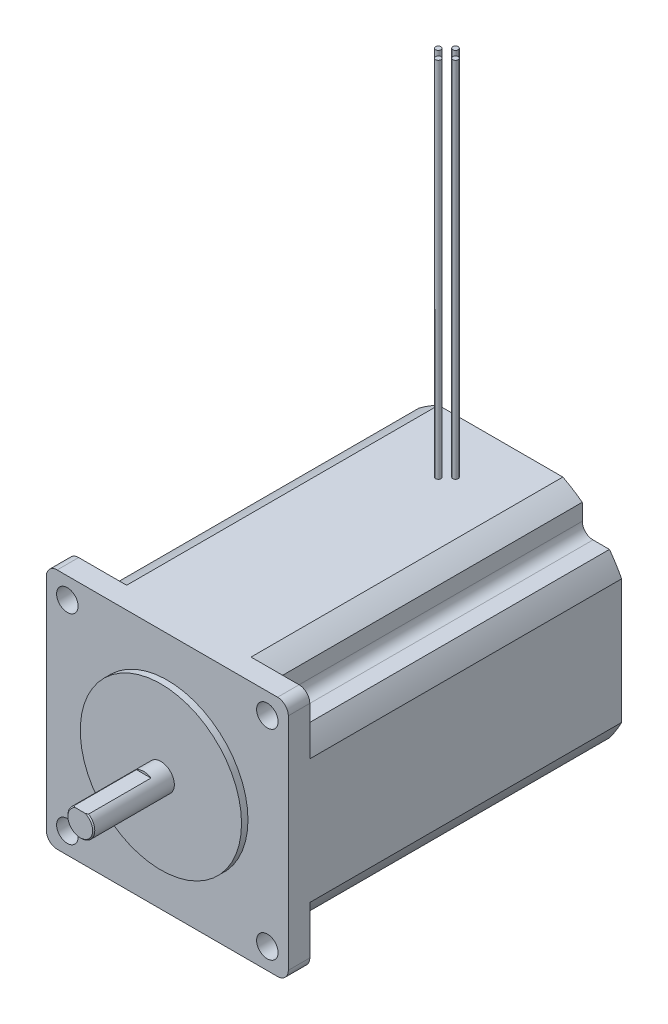
from build123d import *

# Parameters (mm, degrees)
SKETCH1_W           = 57.15
SKETCH1_H           = 78.74
BOSS_EXTRUDE1_DEPTH = 57.15
CUT_EXTRUDE1_DEPTH  = 73.66
CUT_EXTRUDE2_DEPTH  = 73.66
CUT_EXTRUDE3_DEPTH  = 73.66
CUT_EXTRUDE4_DEPTH  = 73.66
CUT_EXTRUDE5_DEPTH  = 73.66
CUT_EXTRUDE6_DEPTH  = 73.66
CUT_EXTRUDE7_DEPTH  = 73.66
CUT_EXTRUDE8_DEPTH  = 73.66
SKETCH10_R          = 19.05
BOSS_EXTRUDE2_DEPTH = 1.524
SKETCH11_R          = 3.175
BOSS_EXTRUDE3_DEPTH = 19.05
CUT_EXTRUDE9_DEPTH  = 14.986
SKETCH13_W          = 0.635
SKETCH13_H          = 85.725
SKETCH14_W          = 0.635
SKETCH14_H          = 85.725
SKETCH15_W          = 0.635
SKETCH15_H          = 85.725
SKETCH16_W          = 0.635
SKETCH16_H          = 85.725
HOLE1_D             = 5.08
HOLE1_DEPTH         = 25.654
HOLE2_D             = 5.08
HOLE2_DEPTH         = 25.654
HOLE3_D             = 5.08
HOLE3_DEPTH         = 25.654
HOLE4_D             = 5.08
HOLE4_DEPTH         = 25.654
CHAMFER1_SIZE       = 0.254
FILLET1_R           = 2.54
FILLET2_R           = 2.54
FILLET3_R           = 2.54
FILLET4_R           = 2.54
FILLET5_R           = 2.54
FILLET6_R           = 2.54
FILLET7_R           = 2.54
FILLET8_R           = 2.54


with BuildPart() as part:
    # Sketch1 → Boss-Extrude1 (new body)
    with BuildSketch(Plane.XZ.offset(28.575)):
        with Locations((0, 39.37)):
            Rectangle(SKETCH1_W, SKETCH1_H)
    extrude(amount=-BOSS_EXTRUDE1_DEPTH)

    # Sketch2 → Cut-Extrude1 (cut)
    with BuildSketch(Plane(origin=(0, 0, 0), x_dir=(-1, 0, 0), z_dir=(0, 0, -1))):
        with BuildLine():
            Line((-28.575, -28.575), (-14.692533342, -28.575))
            ThreePointArc((-14.692533342, -28.575), (-22.720047986, -22.720047986), (-28.575, -14.692533342))
            Line((-28.575, -14.692533342), (-28.575, -28.575))
        make_face()
    extrude(amount=-CUT_EXTRUDE1_DEPTH, mode=Mode.SUBTRACT)

    # Sketch3 → Cut-Extrude2 (cut)
    with BuildSketch(Plane(origin=(0, 0, 0), x_dir=(-1, 0, 0), z_dir=(0, 0, -1))):
        with BuildLine():
            Line((-19.2786, -25.7048), (-19.2786, -19.2786))
            Line((-19.2786, -19.2786), (-25.7048, -19.2786))
            ThreePointArc((-25.7048, -19.2786), (-22.720047986, -22.720047986), (-19.2786, -25.7048))
        make_face()
    extrude(amount=-CUT_EXTRUDE2_DEPTH, mode=Mode.SUBTRACT)

    # Sketch4 → Cut-Extrude3 (cut)
    with BuildSketch(Plane(origin=(0, 0, 0), x_dir=(-1, 0, 0), z_dir=(0, 0, -1))):
        with BuildLine():
            Line((-28.575, 28.575), (-28.575, 14.692533342))
            ThreePointArc((-28.575, 14.692533342), (-22.720047986, 22.720047986), (-14.692533342, 28.575))
            Line((-14.692533342, 28.575), (-28.575, 28.575))
        make_face()
    extrude(amount=-CUT_EXTRUDE3_DEPTH, mode=Mode.SUBTRACT)

    # Sketch5 → Cut-Extrude4 (cut)
    with BuildSketch(Plane(origin=(0, 0, 0), x_dir=(-1, 0, 0), z_dir=(0, 0, -1))):
        with BuildLine():
            Line((-25.7048, 19.2786), (-19.2786, 19.2786))
            Line((-19.2786, 19.2786), (-19.2786, 25.7048))
            ThreePointArc((-19.2786, 25.7048), (-22.720047986, 22.720047986), (-25.7048, 19.2786))
        make_face()
    extrude(amount=-CUT_EXTRUDE4_DEPTH, mode=Mode.SUBTRACT)

    # Sketch6 → Cut-Extrude5 (cut)
    with BuildSketch(Plane(origin=(0, 0, 0), x_dir=(-1, 0, 0), z_dir=(0, 0, -1))):
        with BuildLine():
            Line((28.575, 28.575), (14.692533342, 28.575))
            ThreePointArc((14.692533342, 28.575), (22.720047986, 22.720047986), (28.575, 14.692533342))
            Line((28.575, 14.692533342), (28.575, 28.575))
        make_face()
    extrude(amount=-CUT_EXTRUDE5_DEPTH, mode=Mode.SUBTRACT)

    # Sketch7 → Cut-Extrude6 (cut)
    with BuildSketch(Plane(origin=(0, 0, 0), x_dir=(-1, 0, 0), z_dir=(0, 0, -1))):
        with BuildLine():
            Line((19.2786, 25.7048), (19.2786, 19.2786))
            Line((19.2786, 19.2786), (25.7048, 19.2786))
            ThreePointArc((25.7048, 19.2786), (22.720047986, 22.720047986), (19.2786, 25.7048))
        make_face()
    extrude(amount=-CUT_EXTRUDE6_DEPTH, mode=Mode.SUBTRACT)

    # Sketch8 → Cut-Extrude7 (cut)
    with BuildSketch(Plane(origin=(0, 0, 0), x_dir=(-1, 0, 0), z_dir=(0, 0, -1))):
        with BuildLine():
            Line((28.575, -28.575), (28.575, -14.692533342))
            ThreePointArc((28.575, -14.692533342), (22.720047986, -22.720047986), (14.692533342, -28.575))
            Line((14.692533342, -28.575), (28.575, -28.575))
        make_face()
    extrude(amount=-CUT_EXTRUDE7_DEPTH, mode=Mode.SUBTRACT)

    # Sketch9 → Cut-Extrude8 (cut)
    with BuildSketch(Plane(origin=(0, 0, 0), x_dir=(-1, 0, 0), z_dir=(0, 0, -1))):
        with BuildLine():
            Line((25.7048, -19.2786), (19.2786, -19.2786))
            Line((19.2786, -19.2786), (19.2786, -25.7048))
            ThreePointArc((19.2786, -25.7048), (22.720047986, -22.720047986), (25.7048, -19.2786))
        make_face()
    extrude(amount=-CUT_EXTRUDE8_DEPTH, mode=Mode.SUBTRACT)

    # Sketch10 → Boss-Extrude2 (add)
    with BuildSketch(Plane.XY.offset(78.74)):
        Circle(SKETCH10_R)
    extrude(amount=BOSS_EXTRUDE2_DEPTH)

    # Sketch11 → Boss-Extrude3 (add)
    with BuildSketch(Plane.XY.offset(80.264)):
        Circle(SKETCH11_R)
    extrude(amount=BOSS_EXTRUDE3_DEPTH)

    # Sketch12 → Cut-Extrude9 (cut)
    with BuildSketch(Plane.XY.offset(99.314)):
        with BuildLine():
            Line((-1.722711816, 2.667), (1.722711816, 2.667))
            ThreePointArc((1.722711816, 2.667), (0, 3.175), (-1.722711816, 2.667))
        make_face()
    extrude(amount=-CUT_EXTRUDE9_DEPTH, mode=Mode.SUBTRACT)

    # Sketch13 → Revolve1 (revolve)
    with BuildSketch(Plane(origin=(0, 0, 12.7), x_dir=(-1, 0, 0), z_dir=(0, 0, -1))):
        with Locations((1.7145, 71.4375)):
            Rectangle(SKETCH13_W, SKETCH13_H)
    revolve(axis=Axis((-2.032, 28.575, 12.7), (0, 1, 0)))

    # Sketch14 → Revolve2 (revolve)
    with BuildSketch(Plane(origin=(0, 0, 12.7), x_dir=(-1, 0, 0), z_dir=(0, 0, -1))):
        with Locations((-2.3495, 71.4375)):
            Rectangle(SKETCH14_W, SKETCH14_H)
    revolve(axis=Axis((2.032, 28.575, 12.7), (0, 1, 0)))

    # Sketch15 → Revolve3 (revolve)
    with BuildSketch(Plane(origin=(0, 0, 14.732), x_dir=(-1, 0, 0), z_dir=(0, 0, -1))):
        with Locations((-0.3175, 71.4375)):
            Rectangle(SKETCH15_W, SKETCH15_H)
    revolve(axis=Axis((0, 28.575, 14.732), (0, 1, 0)))

    # Sketch16 → Revolve4 (revolve)
    with BuildSketch(Plane(origin=(0, 0, 10.668), x_dir=(-1, 0, 0), z_dir=(0, 0, -1))):
        with Locations((-0.3175, 71.4375)):
            Rectangle(SKETCH16_W, SKETCH16_H)
    revolve(axis=Axis((0, 28.575, 10.668), (0, 1, 0)))

    # Hole1
    with Locations(Plane(origin=(0, 0, 73.66), x_dir=(-1, 0, 0), z_dir=(0, 0, -1))):
        with Locations((23.622, -23.622)):
            Hole(HOLE1_D / 2, depth=HOLE1_DEPTH)

    # Hole2
    with Locations(Plane(origin=(0, 0, 73.66), x_dir=(-1, 0, 0), z_dir=(0, 0, -1))):
        with Locations((23.622, 23.622)):
            Hole(HOLE2_D / 2, depth=HOLE2_DEPTH)

    # Hole3
    with Locations(Plane(origin=(0, 0, 73.66), x_dir=(-1, 0, 0), z_dir=(0, 0, -1))):
        with Locations((-23.622, 23.622)):
            Hole(HOLE3_D / 2, depth=HOLE3_DEPTH)

    # Hole4
    with Locations(Plane(origin=(0, 0, 73.66), x_dir=(-1, 0, 0), z_dir=(0, 0, -1))):
        with Locations((-23.622, -23.622)):
            Hole(HOLE4_D / 2, depth=HOLE4_DEPTH)

    # Chamfer1
    chamfer1_edges = [part.edges().sort_by_distance(p)[0] for p in [
        (-1.51838977, -2.78838977, 99.314),
    ]]
    chamfer(chamfer1_edges, length=CHAMFER1_SIZE)

    # Fillet1
    fillet1_edges = [part.edges().sort_by_distance(p)[0] for p in [
        (-28.575, 28.575, 76.2),
    ]]
    fillet(fillet1_edges, radius=FILLET1_R)

    # Fillet2
    fillet2_edges = [part.edges().sort_by_distance(p)[0] for p in [
        (-28.575, -28.575, 76.2),
    ]]
    fillet(fillet2_edges, radius=FILLET2_R)

    # Fillet3
    fillet3_edges = [part.edges().sort_by_distance(p)[0] for p in [
        (28.575, 28.575, 76.2),
    ]]
    fillet(fillet3_edges, radius=FILLET3_R)

    # Fillet4
    fillet4_edges = [part.edges().sort_by_distance(p)[0] for p in [
        (-19.2786, 19.2786, 36.83),
    ]]
    fillet(fillet4_edges, radius=FILLET4_R)

    # Fillet5
    fillet5_edges = [part.edges().sort_by_distance(p)[0] for p in [
        (28.575, -28.575, 76.2),
    ]]
    fillet(fillet5_edges, radius=FILLET5_R)

    # Fillet6
    fillet6_edges = [part.edges().sort_by_distance(p)[0] for p in [
        (19.2786, -19.2786, 36.83),
    ]]
    fillet(fillet6_edges, radius=FILLET6_R)

    # Fillet7
    fillet7_edges = [part.edges().sort_by_distance(p)[0] for p in [
        (19.2786, 19.2786, 36.83),
    ]]
    fillet(fillet7_edges, radius=FILLET7_R)

    # Fillet8
    fillet8_edges = [part.edges().sort_by_distance(p)[0] for p in [
        (-19.2786, -19.2786, 36.83),
    ]]
    fillet(fillet8_edges, radius=FILLET8_R)


solid = part.part
